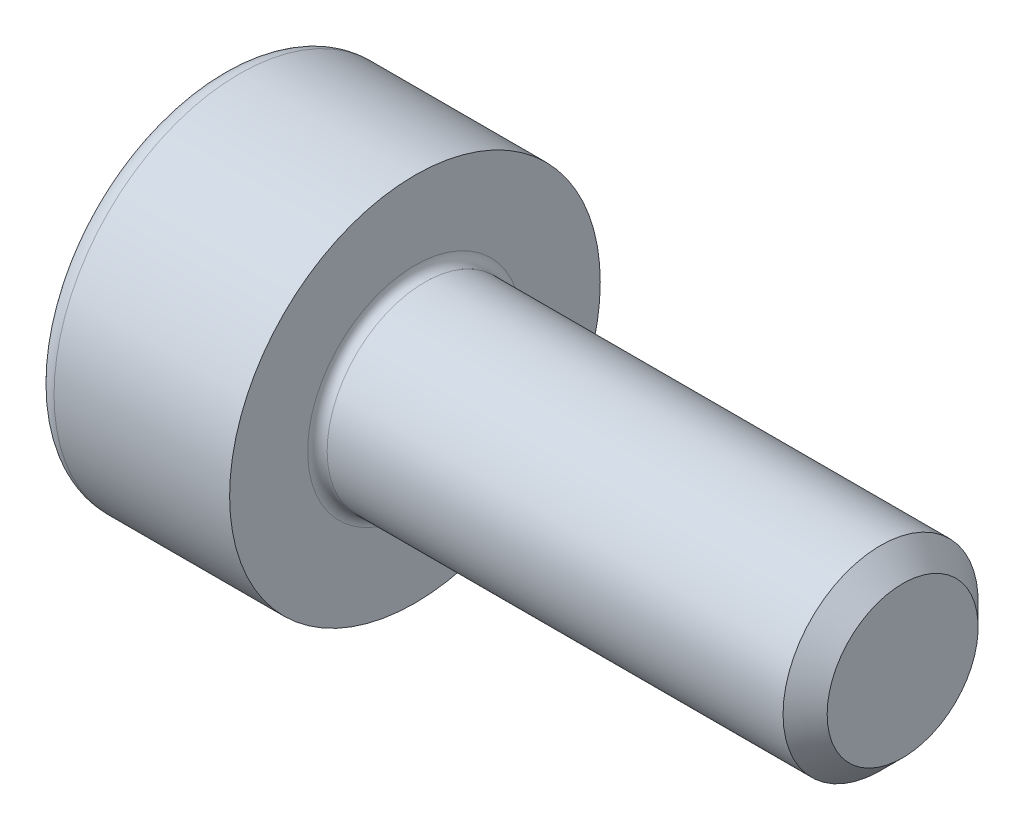
from build123d import *

# Parameters (mm, degrees)
FILLET1_R   = 0.1
FILLET2_R   = 0.2
HEX_2_DEPTH = 1


with BuildPart() as part:
    # BodySke → Base-Revolve (revolve)
    with BuildSketch(Plane.XY):
        Polygon((0, 0), (0, 1.9), (2, 1.9), (2, 1), (6.774, 1), (7, 0.774), (7, 0), align=None)
    revolve(axis=Axis((-31.75, 0, 0), (1, 0, 0)))

    # Fillet1
    fillet1_edges = [part.edges().sort_by_distance(p)[0] for p in [
        (2, -1, 0),
    ]]
    fillet(fillet1_edges, radius=FILLET1_R)

    # Fillet2
    fillet2_edges = [part.edges().sort_by_distance(p)[0] for p in [
        (0, -1.9, 0),
    ]]
    fillet(fillet2_edges, radius=FILLET2_R)

    # Sketch2 → Hex-PreBroach (revolve, cut)
    with BuildSketch(Plane.XY):
        Polygon((0, 0.76), (1, 0.76), (1.438786205, 0), (0, 0), align=None)
    revolve(axis=Axis((0, 0, 0), (1, 0, 0)), mode=Mode.SUBTRACT)

    # Sketch3 → Hex 2 (cut)
    with BuildSketch(Plane(origin=(0, 0, 0), x_dir=(0, 0.5, 0.866025404), z_dir=(-1, 0, 0))):
        Polygon((0.438786205, 0.76), (-0.438786205, 0.76), (-0.877572409, 0), (-0.438786205, -0.76), (0.438786205, -0.76), (0.877572409, 0), align=None)
    extrude(amount=-HEX_2_DEPTH, mode=Mode.SUBTRACT)


solid = part.part
